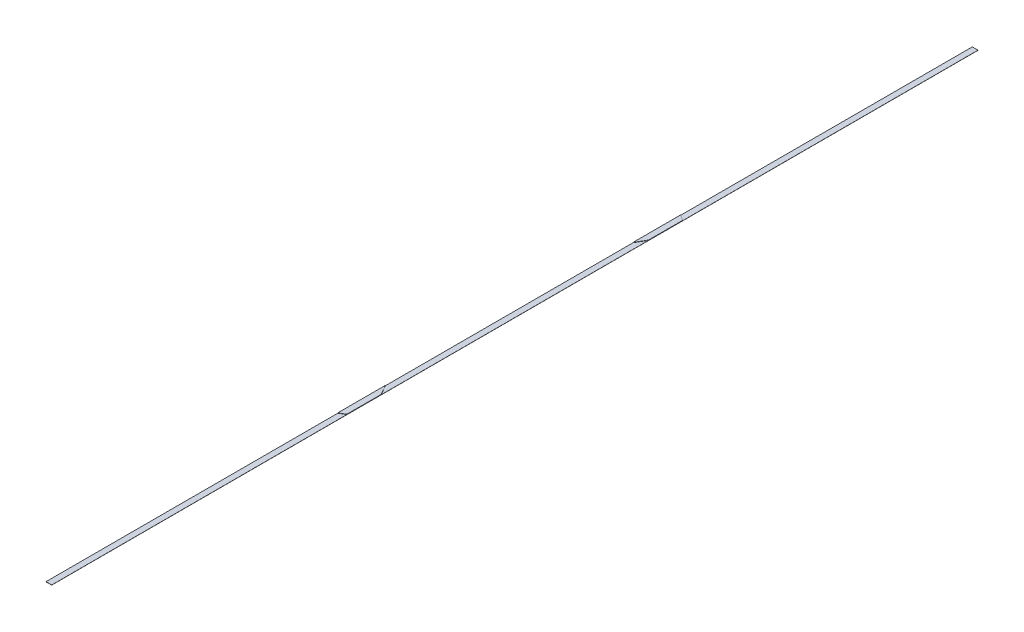
from build123d import *

# Parameters (mm, degrees)
SKETCH1_W           = 50.8
SKETCH1_H           = 8223.93072
BOSS_EXTRUDE1_DEPTH = 1.27
BOSS_EXTRUDE2_DEPTH = 2.65684


with BuildPart() as part:
    # Sketch1 → Boss-Extrude1 (new body)
    with BuildSketch(Plane(origin=(0, 0, 0), x_dir=(1, 0, 0), z_dir=(0, 1, 0))):
        Rectangle(SKETCH1_W, SKETCH1_H)
    extrude(amount=BOSS_EXTRUDE1_DEPTH)

    # Sketch3 → Boss-Extrude2 (add)
    with BuildSketch(Plane(origin=(0, 1.27, 0), x_dir=(1, 0, 0), z_dir=(0, 1, 0))):
        Polygon((-25.4, -1099.047785301), (-25.4, -1521.16536), (25.4, -1491.835966325), (25.4, -1187.035966325), align=None)
        Polygon((-25.4, 1521.16536), (-25.4, 1099.047785301), (25.4, 1187.035966325), (25.4, 1491.835966325), align=None)
    extrude(amount=BOSS_EXTRUDE2_DEPTH)


solid = part.part
